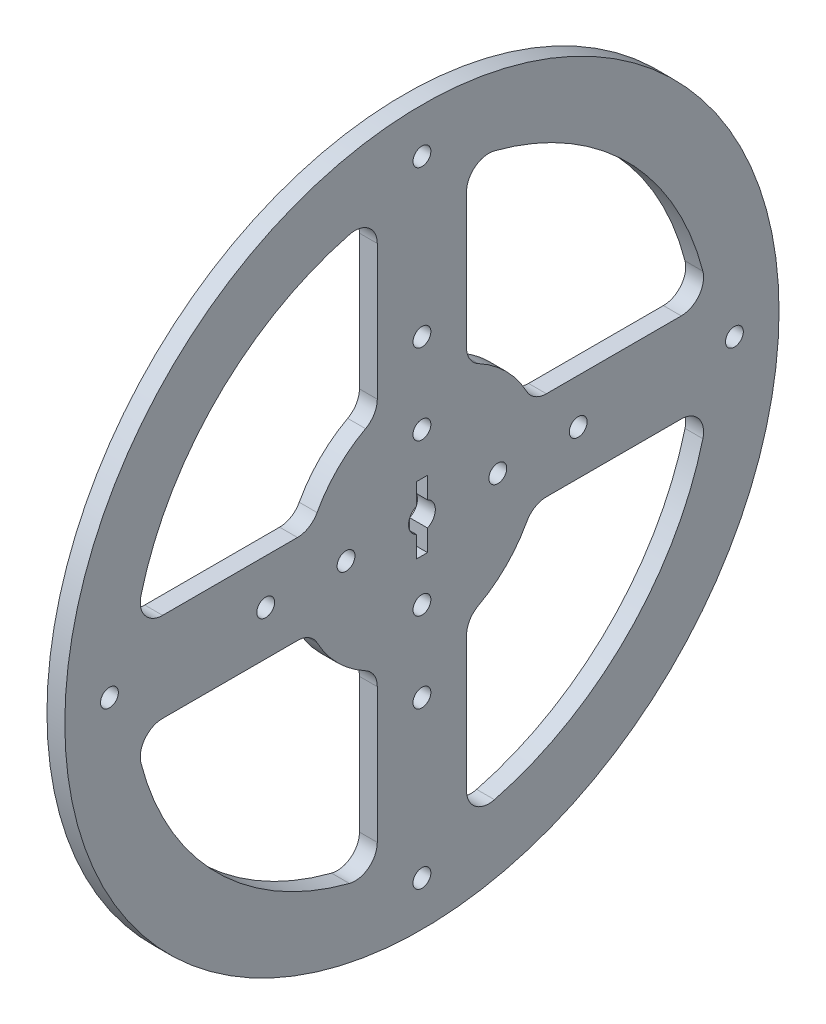
from build123d import *

# Parameters (mm, degrees)
SKETCH1_R           = 80
SKETCH1_R_2         = 2
SKETCH1_R_3         = 3
BOSS_EXTRUDE1_DEPTH = 4
SKETCH2_W           = 2.5
SKETCH2_H           = 15
CUT_EXTRUDE1_DEPTH  = 10


with BuildPart() as part:
    # Sketch1 → Boss-Extrude1 (new body)
    with BuildSketch(Plane(origin=(0, 0, 0), x_dir=(0, 0, -1), z_dir=(1, 0, 0))):
        Circle(SKETCH1_R)
        with Locations((0, 17)):
            Circle(SKETCH1_R_2, mode=Mode.SUBTRACT)
        with Locations((0, 35)):
            Circle(SKETCH1_R_2, mode=Mode.SUBTRACT)
        with Locations((0, 70)):
            Circle(SKETCH1_R_2, mode=Mode.SUBTRACT)
        with Locations((70, 0)):
            Circle(SKETCH1_R_2, mode=Mode.SUBTRACT)
        with Locations((35, 0)):
            Circle(SKETCH1_R_2, mode=Mode.SUBTRACT)
        with Locations((0, -70)):
            Circle(SKETCH1_R_2, mode=Mode.SUBTRACT)
        with Locations((0, -35)):
            Circle(SKETCH1_R_2, mode=Mode.SUBTRACT)
        with Locations((-70, 0)):
            Circle(SKETCH1_R_2, mode=Mode.SUBTRACT)
        with Locations((-35, 0)):
            Circle(SKETCH1_R_2, mode=Mode.SUBTRACT)
        with Locations((17, 0)):
            Circle(SKETCH1_R_2, mode=Mode.SUBTRACT)
        with Locations((0, -17)):
            Circle(SKETCH1_R_2, mode=Mode.SUBTRACT)
        Circle(SKETCH1_R_3, mode=Mode.SUBTRACT)
        with Locations((-17, 0)):
            Circle(SKETCH1_R_2, mode=Mode.SUBTRACT)
        with BuildLine():
            Line((-10, 27.886232268), (-10, 58.094750193))
            ThreePointArc((-10, 58.094750193), (-11.938137822, 62.047597268), (-16.25, 62.935979376))
            ThreePointArc((-16.25, 62.935979376), (-45.961940777, 45.961940777), (-62.935979376, 16.25))
            ThreePointArc((-62.935979376, 16.25), (-62.047597268, 11.938137822), (-58.094750193, 10))
            Line((-58.094750193, 10), (-27.886232268, 10))
            ThreePointArc((-27.886232268, 10), (-25.321364567, 10.707977903), (-23.482844729, 12.631418528))
            ThreePointArc((-23.482844729, 12.631418528), (-18.854664285, 18.854664285), (-12.631418528, 23.482844729))
            ThreePointArc((-12.631418528, 23.482844729), (-10.707977903, 25.321364567), (-10, 27.886232268))
        make_face(mode=Mode.SUBTRACT)
        with BuildLine():
            Line((-10, -58.094750193), (-10, -27.886232268))
            ThreePointArc((-10, -27.886232268), (-10.707977903, -25.321364567), (-12.631418528, -23.482844729))
            ThreePointArc((-12.631418528, -23.482844729), (-18.854664285, -18.854664285), (-23.482844729, -12.631418528))
            ThreePointArc((-23.482844729, -12.631418528), (-25.321364567, -10.707977903), (-27.886232268, -10))
            Line((-27.886232268, -10), (-58.094750193, -10))
            ThreePointArc((-58.094750193, -10), (-62.047597268, -11.938137822), (-62.935979376, -16.25))
            ThreePointArc((-62.935979376, -16.25), (-45.961940777, -45.961940777), (-16.25, -62.935979376))
            ThreePointArc((-16.25, -62.935979376), (-11.938137822, -62.047597268), (-10, -58.094750193))
        make_face(mode=Mode.SUBTRACT)
        with BuildLine():
            Line((10, -58.094750193), (10, -27.886232268))
            ThreePointArc((10, -27.886232268), (10.707977903, -25.321364567), (12.631418528, -23.482844729))
            ThreePointArc((12.631418528, -23.482844729), (18.854664285, -18.854664285), (23.482844729, -12.631418528))
            ThreePointArc((23.482844729, -12.631418528), (25.321364567, -10.707977903), (27.886232268, -10))
            Line((27.886232268, -10), (58.094750193, -10))
            ThreePointArc((58.094750193, -10), (62.047597268, -11.938137822), (62.935979376, -16.25))
            ThreePointArc((62.935979376, -16.25), (45.961940777, -45.961940777), (16.25, -62.935979376))
            ThreePointArc((16.25, -62.935979376), (11.938137822, -62.047597268), (10, -58.094750193))
        make_face(mode=Mode.SUBTRACT)
        with BuildLine():
            Line((10, 27.886232268), (10, 58.094750193))
            ThreePointArc((10, 58.094750193), (11.938137822, 62.047597268), (16.25, 62.935979376))
            ThreePointArc((16.25, 62.935979376), (45.961940777, 45.961940777), (62.935979376, 16.25))
            ThreePointArc((62.935979376, 16.25), (62.047597268, 11.938137822), (58.094750193, 10))
            Line((58.094750193, 10), (27.886232268, 10))
            ThreePointArc((27.886232268, 10), (25.321364567, 10.707977903), (23.482844729, 12.631418528))
            ThreePointArc((23.482844729, 12.631418528), (18.854664285, 18.854664285), (12.631418528, 23.482844729))
            ThreePointArc((12.631418528, 23.482844729), (10.707977903, 25.321364567), (10, 27.886232268))
        make_face(mode=Mode.SUBTRACT)
    extrude(amount=BOSS_EXTRUDE1_DEPTH)

    # Sketch2 → Cut-Extrude1 (cut)
    with BuildSketch(Plane.ZY):
        Rectangle(SKETCH2_W, SKETCH2_H)
    extrude(amount=-CUT_EXTRUDE1_DEPTH, mode=Mode.SUBTRACT)


solid = part.part
